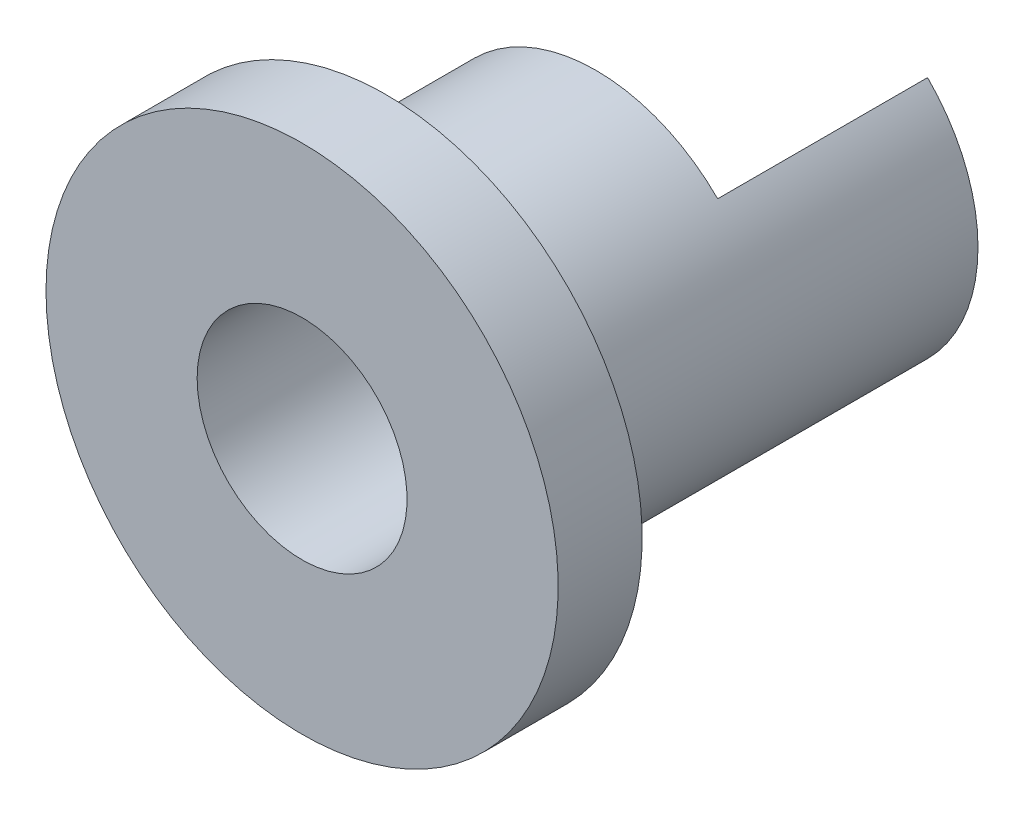
from build123d import *

# Parameters (mm, degrees)
BOSS_EXTRU_1_DEPTH = 5


with BuildPart() as part:
    # Esquisse1 → Révolution1 (revolve)
    with BuildSketch(Plane(origin=(0, 0, 0), x_dir=(1, 0, 0), z_dir=(0, 1, 0))):
        Polygon((-2.5, 0), (-6.1, 0), (-6.1, 2), (-4.1, 2), (-4.1, 7), (-2.5, 7), align=None)
    revolve(axis=Axis((0, 0, -7.597402597), (0, 0, 1)))

    # Esquisse2 → Boss.-Extru.1 (add)
    with BuildSketch(Plane(origin=(0, 0, -7), x_dir=(-1, 0, 0), z_dir=(0, 0, -1))):
        with BuildLine():
            Line((-2.899137803, 2.899137803), (-1.767766953, 1.767766953))
            ThreePointArc((-1.767766953, 1.767766953), (-2.5, 0), (-1.767766953, -1.767766953))
            Line((-1.767766953, -1.767766953), (-2.899137803, -2.899137803))
            ThreePointArc((-2.899137803, -2.899137803), (-4.1, 0), (-2.899137803, 2.899137803))
        make_face()
    extrude(amount=BOSS_EXTRU_1_DEPTH)


solid = part.part
